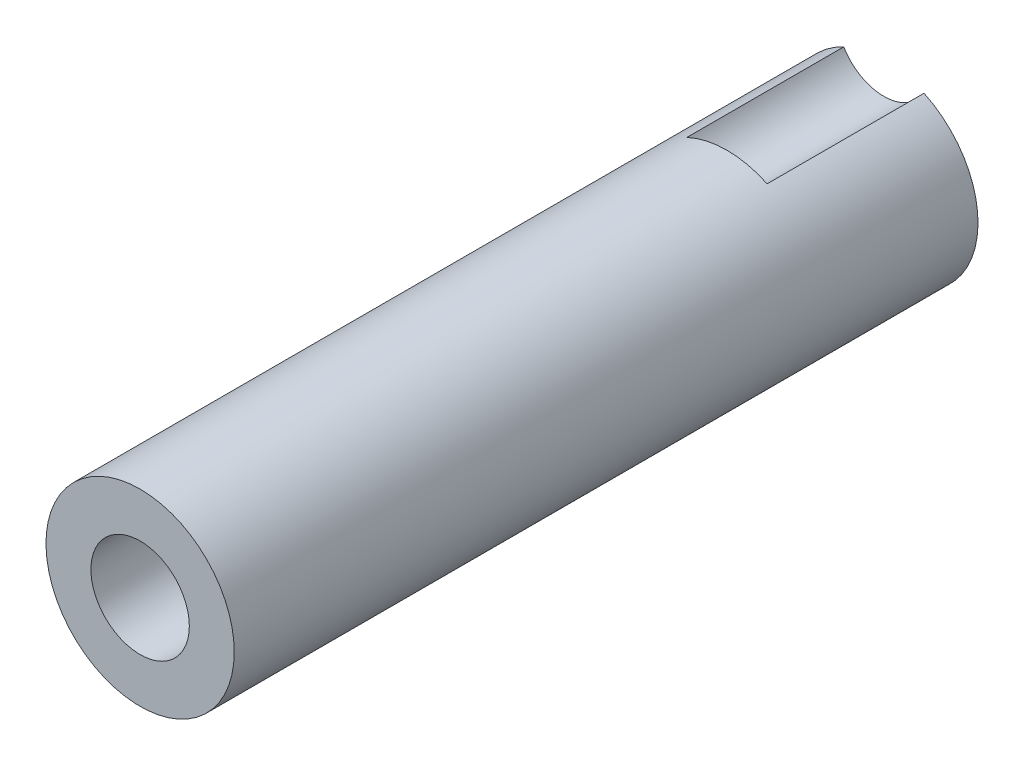
from build123d import *
from build123d.topology import SkipClean

# Parameters (mm, degrees)
SKETCH1_R           = 12.5349
BOSS_EXTRUDE1_DEPTH = 6.4389
BOSS_EXTRUDE2_DEPTH = 4.0386
SKETCH3_R           = 6.4008
BOSS_EXTRUDE3_DEPTH = 44.1325
SKETCH4_R           = 3.175
CUT_EXTRUDE1_DEPTH  = 10.668
CUT_EXTRUDE2_DEPTH  = 51.5714
SKETCH6_R           = 3.34645
CUT_EXTRUDE3_DEPTH  = 51.5714
SKETCH7_R           = 12.5349
SKETCH7_R_2         = 6.4008
CUT_EXTRUDE4_DEPTH  = 51.5714
SKETCH11_R          = 0.848438372
CUT_EXTRUDE5_DEPTH  = 5.08


with BuildPart() as part:
    # Sketch1 → Boss-Extrude1 (new body)
    with BuildSketch(Plane.XY):
        Circle(SKETCH1_R)
    extrude(amount=BOSS_EXTRUDE1_DEPTH)

    # Sketch2 → Boss-Extrude2 (add)
    with BuildSketch(Plane.XY.offset(6.4389)):
        with BuildLine():
            Line((-9.8298, 7.778094238), (9.8298, 7.778094238))
            ThreePointArc((9.8298, 7.778094238), (0, 12.5349), (-9.8298, 7.778094238))
        make_face()
    extrude(amount=BOSS_EXTRUDE2_DEPTH)

    # Sketch3 → Boss-Extrude3 (add)
    with BuildSketch(Plane.XY.offset(6.4389)):
        Circle(SKETCH3_R)
    extrude(amount=BOSS_EXTRUDE3_DEPTH)

    # Sketch4 → Cut-Extrude1 (cut)
    with BuildSketch(Plane(origin=(0, 0, 0), x_dir=(-1, 0, 0), z_dir=(0, 0, -1))):
        with Locations((0, 7.41045)):
            Circle(SKETCH4_R)
    extrude(amount=-CUT_EXTRUDE1_DEPTH, mode=Mode.SUBTRACT)

    # Sketch5 → Cut-Extrude2 (cut, through all)
    with BuildSketch(Plane(origin=(0, 0, 0), x_dir=(-1, 0, 0), z_dir=(0, 0, -1))):
        with BuildLine():
            Line((2.667, -12.247890798), (-2.667, -12.247890798))
            ThreePointArc((-2.667, -12.247890798), (0, -12.5349), (2.667, -12.247890798))
        make_face()
    extrude(amount=-CUT_EXTRUDE2_DEPTH, mode=Mode.SUBTRACT)

    # Sketch6 → Cut-Extrude3 (cut, through all)
    with BuildSketch(Plane.XY.offset(50.5714)):
        Circle(SKETCH6_R)
    extrude(amount=-CUT_EXTRUDE3_DEPTH, mode=Mode.SUBTRACT)

    # Sketch7 → Cut-Extrude4 (cut, through all)
    with SkipClean():  # keep this step's faces unmerged: merging them makes the solid invalid here
        with BuildSketch(Plane(origin=(0, 0, 0), x_dir=(-1, 0, 0), z_dir=(0, 0, -1))):
            Circle(SKETCH7_R)
            with Locations(Location((0, 0, 0), (0, 0, 64.753808508))):  # turned: the seam where the file's is
                Circle(SKETCH7_R_2, mode=Mode.SUBTRACT)
        extrude(amount=-CUT_EXTRUDE4_DEPTH, mode=Mode.SUBTRACT)

    # Sketch11 → Cut-Extrude5 (cut)
    with SkipClean():  # keep this step's faces unmerged: merging them makes the solid invalid here
        with BuildSketch(Plane(origin=(0, -6.4008, 0), x_dir=(-1, 0, 0), z_dir=(0, 1, 0))):
            with Locations(Location((0, 42.069683216, 0), (0, 0, 270))):  # turned: the seam where the file's is
                Circle(SKETCH11_R)
        extrude(amount=CUT_EXTRUDE5_DEPTH, mode=Mode.SUBTRACT)


solid = part.part
